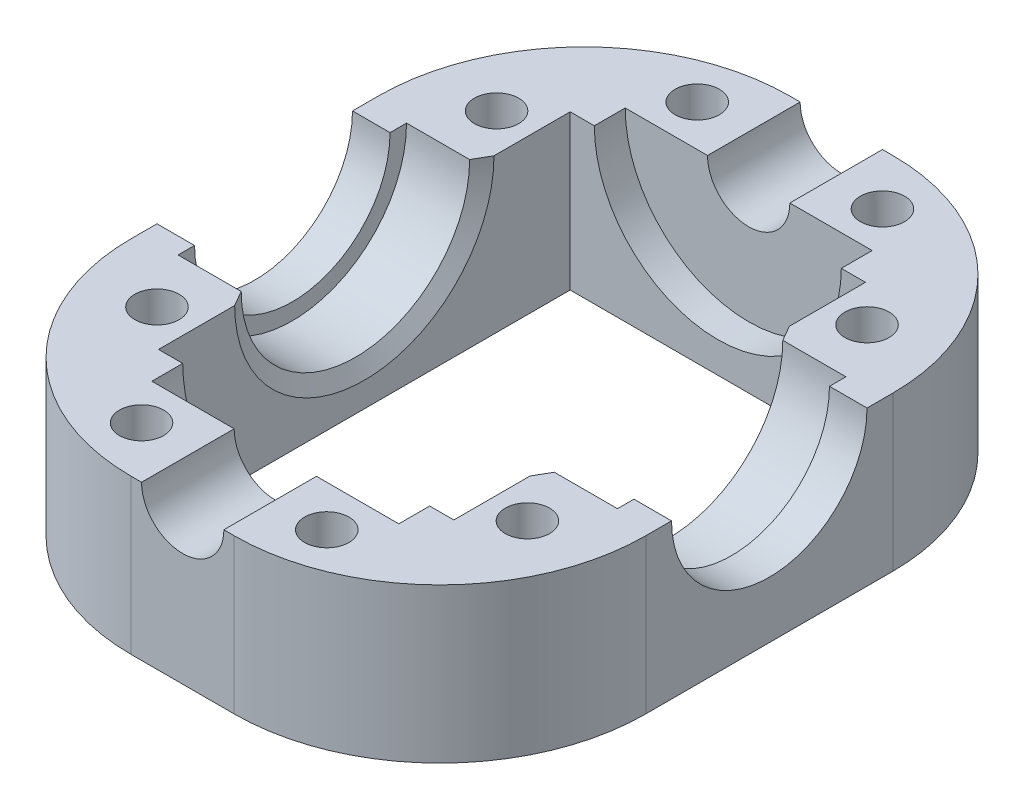
from build123d import *

# Parameters (mm, degrees)
SKETCH1_W             = 50
SKETCH1_H             = 64
SKETCH1_W_2           = 28.7
SKETCH1_H_2           = 40
BOSS_EXTRUDE1_DEPTH   = 15
SKETCH3_W             = 7
SKETCH3_H             = 11.1
SKETCH4_R             = 9.5
CUT_EXTRUDE2_DEPTH    = 51
SKETCH5_R             = 4
CUT_EXTRUDE3_DEPTH    = 65
SKETCH8_R             = 2.15
CUT_EXTRUDE6_DEPTH    = 16
FILLET1_R             = 20
CHAMFER1_SIZE         = 1.5
CHAMFER1_SIZE2        = 0.866025404
CHAMFER1_PART_2_SIZE  = 1.5
CHAMFER1_PART_2_SIZE2 = 0.866025404
SKETCH9_W             = 12
SKETCH9_H             = 3


with BuildPart() as part:
    # Sketch1 → Boss-Extrude1 (new body)
    with BuildSketch(Plane(origin=(0, 0, 0), x_dir=(1, 0, 0), z_dir=(0, 1, 0))):
        Rectangle(SKETCH1_W, SKETCH1_H)
        Rectangle(SKETCH1_W_2, SKETCH1_H_2, mode=Mode.SUBTRACT)
    extrude(amount=BOSS_EXTRUDE1_DEPTH)

    # Sketch3 → Cut-Revolve1 (revolve, cut)
    with BuildSketch(Plane(origin=(0, 15, 0), x_dir=(1, 0, 0), z_dir=(0, 1, 0))):
        with Locations((17.85, -5.55)):
            Rectangle(SKETCH3_W, SKETCH3_H)
        with Locations((-17.85, -5.55)):
            Rectangle(SKETCH3_W, SKETCH3_H)
    revolve(axis=Axis((14.35, 15, 0), (1, 0, 0)), mode=Mode.SUBTRACT)

    # Sketch4 → Cut-Extrude2 (cut, through all)
    with BuildSketch(Plane(origin=(25, 0, 0), x_dir=(0, 0, -1), z_dir=(1, 0, 0))):
        with Locations((0, 15)):
            Circle(SKETCH4_R)
    extrude(amount=-CUT_EXTRUDE2_DEPTH, mode=Mode.SUBTRACT)

    # Sketch5 → Cut-Extrude3 (cut, through all)
    with BuildSketch(Plane.XY.offset(32)):
        with Locations((0, 15)):
            Circle(SKETCH5_R)
    extrude(amount=-CUT_EXTRUDE3_DEPTH, mode=Mode.SUBTRACT)

    # Sketch8 → Cut-Extrude6 (cut, through all)
    with BuildSketch(Plane(origin=(0, 15, 0), x_dir=(1, 0, 0), z_dir=(0, 1, 0))):
        with Locations(Location((18, 16.5, 0), (0, 0, 270))):  # turned: the seam where the file's is
            Circle(SKETCH8_R)
        with Locations(Location((18, -16.5, 0), (0, 0, 270))):  # turned: the seam where the file's is
            Circle(SKETCH8_R)
        with Locations(Location((-18, -16.5, 0), (0, 0, 270))):  # turned: the seam where the file's is
            Circle(SKETCH8_R)
        with Locations(Location((-18, 16.5, 0), (0, 0, 270))):  # turned: the seam where the file's is
            Circle(SKETCH8_R)
        with Locations(Location((9, -27, 0), (0, 0, 270))):  # turned: the seam where the file's is
            Circle(SKETCH8_R)
        with Locations(Location((-9, -27, 0), (0, 0, 270))):  # turned: the seam where the file's is
            Circle(SKETCH8_R)
        with Locations(Location((-9, 27, 0), (0, 0, 270))):  # turned: the seam where the file's is
            Circle(SKETCH8_R)
        with Locations(Location((9, 27, 0), (0, 0, 270))):  # turned: the seam where the file's is
            Circle(SKETCH8_R)
    extrude(amount=-CUT_EXTRUDE6_DEPTH, mode=Mode.SUBTRACT)

    # Fillet1
    fillet1_edges = [part.edges().sort_by_distance(p)[0] for p in [
        (-25, 7.5, -32),
        (25, 7.5, -32),
        (25, 7.5, 32),
        (-25, 7.5, 32),
    ]]
    fillet(fillet1_edges, radius=FILLET1_R)

    # Chamfer1
    chamfer1_edges = [part.edges().sort_by_distance(p)[0] for p in [
        (14.35, 3.9, 0),
    ]]
    chamfer1_side = [part.faces().sort_by_distance(p)[0] for p in [
        (14.35, 0.427200187, 0),
    ]]
    chamfer(chamfer1_edges, length=CHAMFER1_SIZE, length2=CHAMFER1_SIZE2, reference=chamfer1_side[0])

    # Chamfer1 part 2
    chamfer1_part_2_edges = [part.edges().sort_by_distance(p)[0] for p in [
        (-14.35, 3.9, 0),
    ]]
    chamfer1_part_2_side = [part.faces().sort_by_distance(p)[0] for p in [
        (-14.35, 0.427200187, 0),
    ]]
    chamfer(chamfer1_part_2_edges, length=CHAMFER1_PART_2_SIZE, length2=CHAMFER1_PART_2_SIZE2, reference=chamfer1_part_2_side[0])

    # Sketch9 → Cut-Revolve2 (revolve, cut)
    with BuildSketch(Plane(origin=(0, 15, 0), x_dir=(1, 0, 0), z_dir=(0, 1, 0))):
        with Locations((-6, -21.5)):
            Rectangle(SKETCH9_W, SKETCH9_H)
        with Locations((-6, 21.5)):
            Rectangle(SKETCH9_W, SKETCH9_H)
    revolve(axis=Axis((0, 15, -29.871415895), (0, 0, 1)), mode=Mode.SUBTRACT)


solid = part.part
